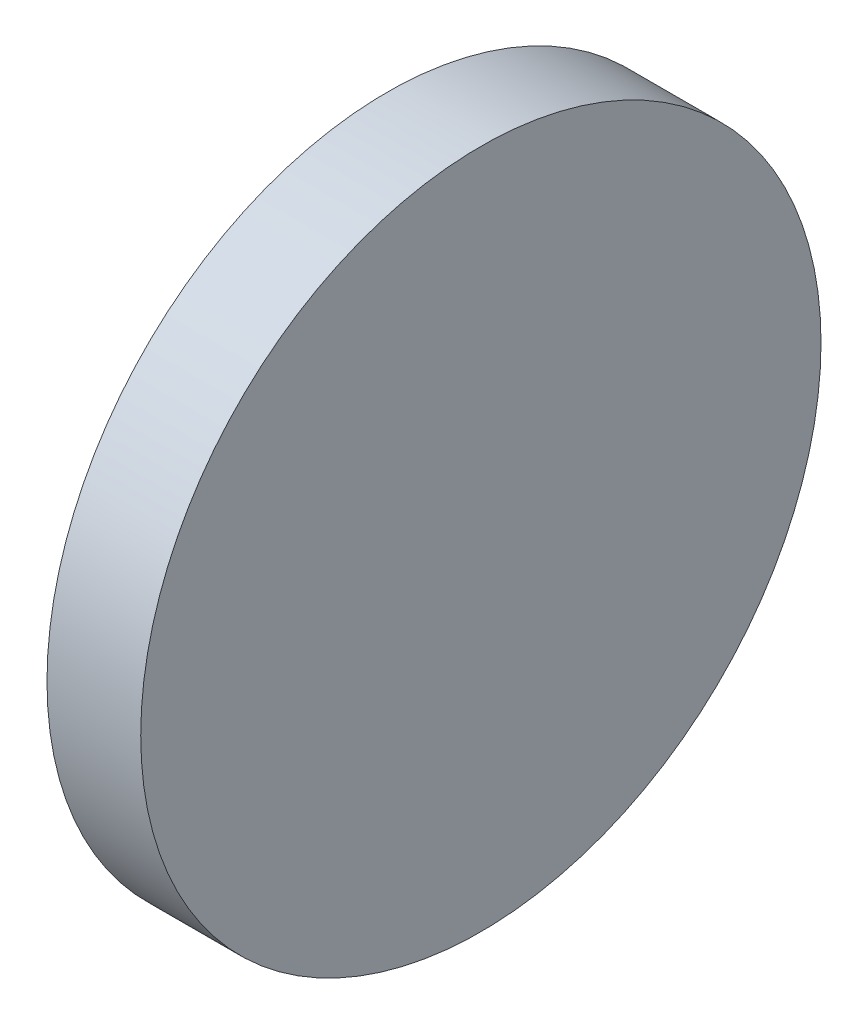
from build123d import *

# Parameters (mm, degrees)
SKETCH_1_W = 3.5
SKETCH_1_H = 12.7


with BuildPart() as part:
    # 草图1 → 旋转2 (revolve)
    with BuildSketch(Plane.XY, mode=Mode.PRIVATE) as revolve_2_sk:
        with Locations((1.75, 6.35)):
            Rectangle(SKETCH_1_W, SKETCH_1_H)
    revolve(revolve_2_sk.sketch.rotate(Axis((0, 0, 0), (1, 0, 0)), 90), axis=Axis((0, 0, 0), (1, 0, 0)))  # turned: the seam where the file's is


solid = part.part
